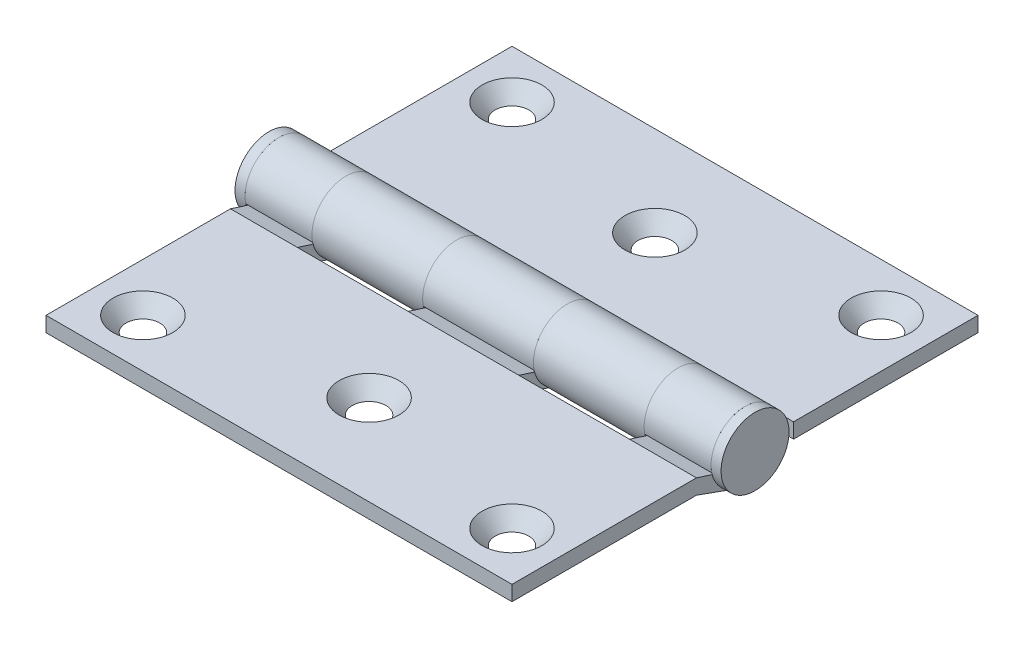
from build123d import *

# Parameters (mm, degrees)
LEFT_LEAF_DEPTH                              = 38.1
SKETCH2_W                                    = 18.10512
SKETCH2_H                                    = 13.49375
CUT_EXTRUDE1_DEPTH                           = 6.55625
CUT_EXTRUDE1_DEPTH_BACK                      = 6.55625
RIGHT_LEAF_DEPTH                             = 18.10512
EXTRUDE3_START                               = -38.1
SKETCH4_W                                    = 30.1625
SKETCH4_H                                    = 2.4638
EXTRUDE3_DEPTH                               = 76.2
SKETCH6_W                                    = 76.2
SKETCH6_H                                    = 2.9765625
SKETCH7_W                                    = 1.642533333
SKETCH7_H                                    = 5.55625
CSK_FOR_10_FLAT_HEAD_MACHINE_SCREW1_AT_COUNT = 2
CSK_FOR_10_FLAT_HEAD_MACHINE_SCREW1_AT_PITCH = 60.3504
CSK_FOR_10_FLAT_HEAD_MACHINE_SCREW1_2_COUNT  = 2
CSK_FOR_10_FLAT_HEAD_MACHINE_SCREW1_2_PITCH  = 85.348354175
CSK_FOR_10_FLAT_HEAD_MACHINE_SCREW1_3_COUNT  = 2
CSK_FOR_10_FLAT_HEAD_MACHINE_SCREW1_3_PITCH  = 60.3504
CSK_FOR_10_FLAT_HEAD_MACHINE_SCREW1_4_COUNT  = 2
CSK_FOR_10_FLAT_HEAD_MACHINE_SCREW1_4_PITCH  = 61.460694442
CSK_FOR_10_FLAT_HEAD_MACHINE_SCREW1_5_COUNT  = 2
CSK_FOR_10_FLAT_HEAD_MACHINE_SCREW1_5_PITCH  = 30.93348779


with BuildPart() as part:
    # Sketch1 → Left Leaf (new body, symmetric)
    with BuildSketch(Plane(origin=(0, 0, 0), x_dir=(0, 0, -1), z_dir=(1, 0, 0))):
        with BuildLine():
            Line((-7.9375, -3.048), (-1.881879584, -5.227852647))
            ThreePointArc((-1.881879584, -5.227852647), (4.20000577, 3.637563139), (-5.442995818, -1.116114057))
            Line((-5.442995818, -1.116114057), (-1.975984457, -2.226074963))
            ThreePointArc((-1.975984457, -2.226074963), (1.473554552, 2.586225299), (-0.907567655, -2.834827202))
            Line((-0.907567655, -2.834827202), (-7.9375, -0.5842))
            Line((-7.9375, -0.5842), (-38.1, -0.5842))
            Line((-38.1, -0.5842), (-38.1, -3.048))
            Line((-38.1, -3.048), (-7.9375, -3.048))
        make_face()
    extrude(amount=LEFT_LEAF_DEPTH, both=True)

    # Sketch2 → Cut-Extrude1 (cut, two sides)
    with BuildSketch(Plane(origin=(0, 0, 0), x_dir=(1, 0, 0), z_dir=(0, 1, 0))) as cut_extrude1_sk:
        with Locations((18.10512, -1.190625)):
            Rectangle(SKETCH2_W, SKETCH2_H)
        with Locations((-18.10512, -1.190625)):
            Rectangle(SKETCH2_W, SKETCH2_H)
    extrude(amount=CUT_EXTRUDE1_DEPTH, mode=Mode.SUBTRACT)
    extrude(cut_extrude1_sk.sketch, amount=-CUT_EXTRUDE1_DEPTH_BACK, mode=Mode.SUBTRACT)

    # Sketch9 → CSK for #10 Flat Head Machine Screw1 (revolve, cut)
    with BuildSketch(Plane(origin=(-30.1752, -0.5842, 30.1752), x_dir=(0, 0, 1), z_dir=(1, 0, 0))):
        Polygon((0, 0), (0, 4.97205), (2.5527, 4.97205), (2.5527, 2.688180894), (4.8895, 0), align=None)
    csk_for_10_flat_head_machine_screw1 = revolve(axis=Axis((-30.1752, 5.7658, 30.1752), (0, -1, 0)), mode=Mode.SUBTRACT)

    # CSK for _10 Flat Head Machine Screw1 3: CSK for #10 Flat Head Machine Screw1 ×2
    with Locations(*[(i * CSK_FOR_10_FLAT_HEAD_MACHINE_SCREW1_3_PITCH, 0, 0) for i in range(1, CSK_FOR_10_FLAT_HEAD_MACHINE_SCREW1_3_COUNT)]):
        add(csk_for_10_flat_head_machine_screw1, mode=Mode.SUBTRACT)

    # CSK for _10 Flat Head Machine Screw1 5: CSK for #10 Flat Head Machine Screw1 ×2
    with Locations(*[Vector(0.975486508, 0, -0.220059246) * (i * CSK_FOR_10_FLAT_HEAD_MACHINE_SCREW1_5_PITCH) for i in range(1, CSK_FOR_10_FLAT_HEAD_MACHINE_SCREW1_5_COUNT)]):
        add(csk_for_10_flat_head_machine_screw1, mode=Mode.SUBTRACT)


with BuildPart() as body_2:
    # Sketch3 → Right Leaf (new body)
    with BuildSketch(Plane(origin=(27.15768, 0, 0), x_dir=(0, 0, -1), z_dir=(1, 0, 0))):
        with BuildLine():
            Line((7.9375, -3.048), (1.881879584, -5.227852647))
            ThreePointArc((1.881879584, -5.227852647), (-4.20000577, 3.637563139), (5.442995818, -1.116114057))
            Line((5.442995818, -1.116114057), (1.975984457, -2.226074963))
            ThreePointArc((1.975984457, -2.226074963), (-1.473554552, 2.586225299), (0.907567655, -2.834827202))
            Line((0.907567655, -2.834827202), (7.9375, -0.5842))
            Line((7.9375, -0.5842), (38.1, -0.5842))
            Line((38.1, -0.5842), (38.1, -3.048))
            Line((38.1, -3.048), (7.9375, -3.048))
        make_face()
    extrude(amount=-RIGHT_LEAF_DEPTH)


with BuildPart() as body_3:
    # Mirror1: mirrored copy
    add(body_2.part.mirror(Plane(origin=(0, 0, 0), x_dir=(0, 0, 1), z_dir=(1, 0, 0))))


with BuildPart() as body_4:
    # Sketch4 → Extrude3 (new body)
    with BuildSketch(Plane.ZY.offset(EXTRUDE3_START)):
        with Locations((-23.01875, -1.8161)):
            Rectangle(SKETCH4_W, SKETCH4_H)
    extrude(amount=EXTRUDE3_DEPTH)


with BuildPart() as body_3_1:
    add(body_3.part)

    # Combine1: union body 2, body 4
    add(body_2.part)
    add(body_4.part)

    # CSK for #10 Flat Head Machine Screw1 at: CSK for #10 Flat Head Machine Screw1 ×2
    with Locations(*[(0, 0, -i * CSK_FOR_10_FLAT_HEAD_MACHINE_SCREW1_AT_PITCH) for i in range(1, CSK_FOR_10_FLAT_HEAD_MACHINE_SCREW1_AT_COUNT)]):
        add(csk_for_10_flat_head_machine_screw1, mode=Mode.SUBTRACT)

    # CSK for _10 Flat Head Machine Screw1 2: CSK for #10 Flat Head Machine Screw1 ×2
    with Locations(*[Vector(0.707106781, 0, -0.707106781) * (i * CSK_FOR_10_FLAT_HEAD_MACHINE_SCREW1_2_PITCH) for i in range(1, CSK_FOR_10_FLAT_HEAD_MACHINE_SCREW1_2_COUNT)]):
        add(csk_for_10_flat_head_machine_screw1, mode=Mode.SUBTRACT)

    # CSK for _10 Flat Head Machine Screw1 4: CSK for #10 Flat Head Machine Screw1 ×2
    with Locations(*[Vector(0.490967443, 0, -0.871177921) * (i * CSK_FOR_10_FLAT_HEAD_MACHINE_SCREW1_4_PITCH) for i in range(1, CSK_FOR_10_FLAT_HEAD_MACHINE_SCREW1_4_COUNT)]):
        add(csk_for_10_flat_head_machine_screw1, mode=Mode.SUBTRACT)


with BuildPart() as body_3_2:
    # Sketch6 → Pin (revolve)
    with BuildSketch(Plane(origin=(0, 0, 0), x_dir=(1, 0, 0), z_dir=(0, 1, 0))):
        with Locations((0, -1.48828125)):
            Rectangle(SKETCH6_W, SKETCH6_H)
    revolve(axis=Axis((24.566181471, 0, 0), (-1, 0, 0)))

    # Sketch7 → Spun Pin (revolve)
    with BuildSketch(Plane(origin=(0, 0, 0), x_dir=(1, 0, 0), z_dir=(0, 1, 0))):
        with Locations((-38.921266667, -2.778125)):
            Rectangle(SKETCH7_W, SKETCH7_H)
        with Locations((38.921266667, -2.778125)):
            Rectangle(SKETCH7_W, SKETCH7_H)
    revolve(axis=Axis((24.566181471, 0, 0), (-1, 0, 0)))


solid = Compound([part.part, body_3_1.part, body_3_2.part])
